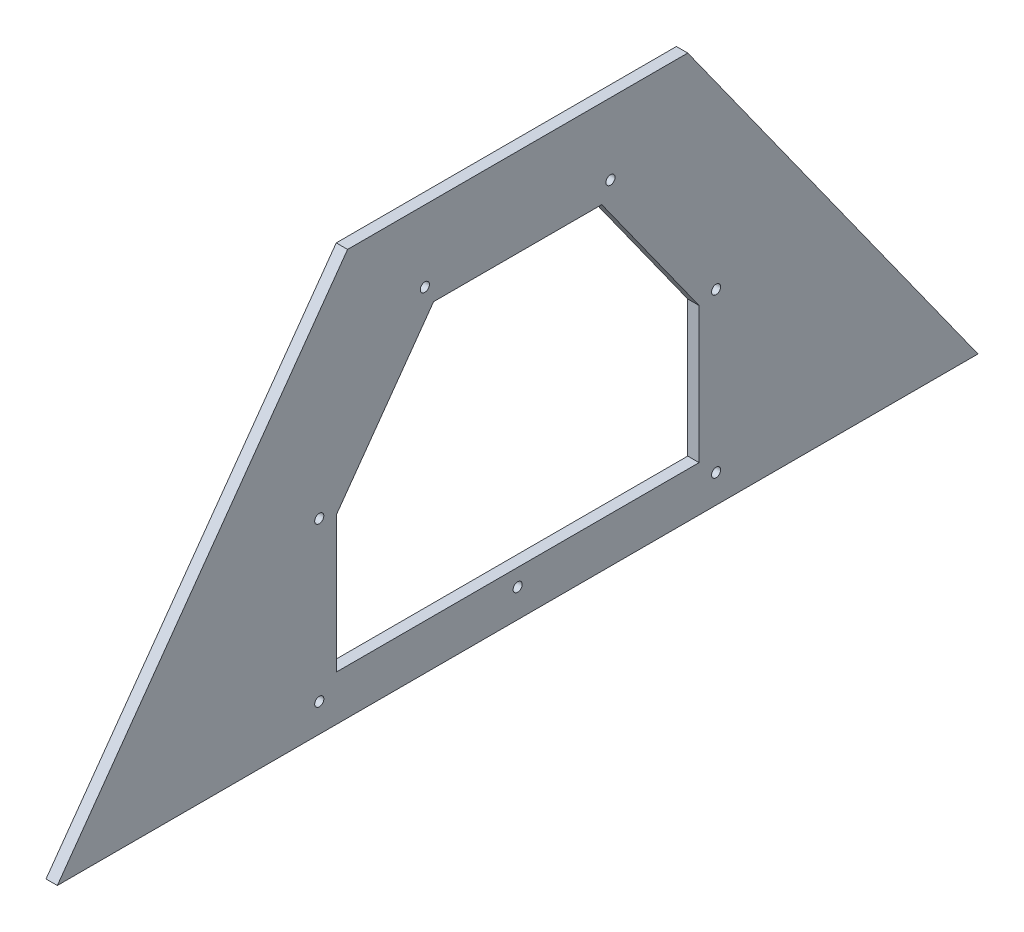
from build123d import *

# Parameters (mm, degrees)
BOSS_EXTRUDE1_DEPTH    = 6.35
CUT_EXTRUDE1_DEPTH     = 7.35
F_10_CLEARANCE_HOLE1_D = 5.1054


with BuildPart() as part:
    # Sketch1 → Boss-Extrude1 (new body)
    with BuildSketch(Plane(origin=(0, 0, 0), x_dir=(0, 0, -1), z_dir=(1, 0, 0))):
        Polygon((257.81, 0), (-257.81, 0), (-95.25, 227.241295543), (95.25, 227.241295543), align=None)
    extrude(amount=BOSS_EXTRUDE1_DEPTH)

    # Sketch3 → Cut-Extrude1 (cut, through all)
    with BuildSketch(Plane(origin=(6.35, 0, 0), x_dir=(0, 0, -1), z_dir=(1, 0, 0))):
        Polygon((-47.089344398, 177.8), (47.089344398, 177.8), (101.6, 101.6), (101.6, 25.4), (-101.6, 25.4), (-101.6, 101.6), align=None)
    extrude(amount=-CUT_EXTRUDE1_DEPTH, mode=Mode.SUBTRACT)

    # #10 Clearance Hole1 (through all)
    with Locations(Plane(origin=(6.35, 0, 0), x_dir=(0, 0, -1), z_dir=(1, 0, 0))):
        with Locations((51.986786112, 187.325), (-51.986786112, 187.325), (111.125, 104.656174089), (111.125, 15.875), (-111.125, 15.875), (-111.125, 104.656174089), (0, 15.875)):
            Hole(F_10_CLEARANCE_HOLE1_D / 2)


solid = part.part
